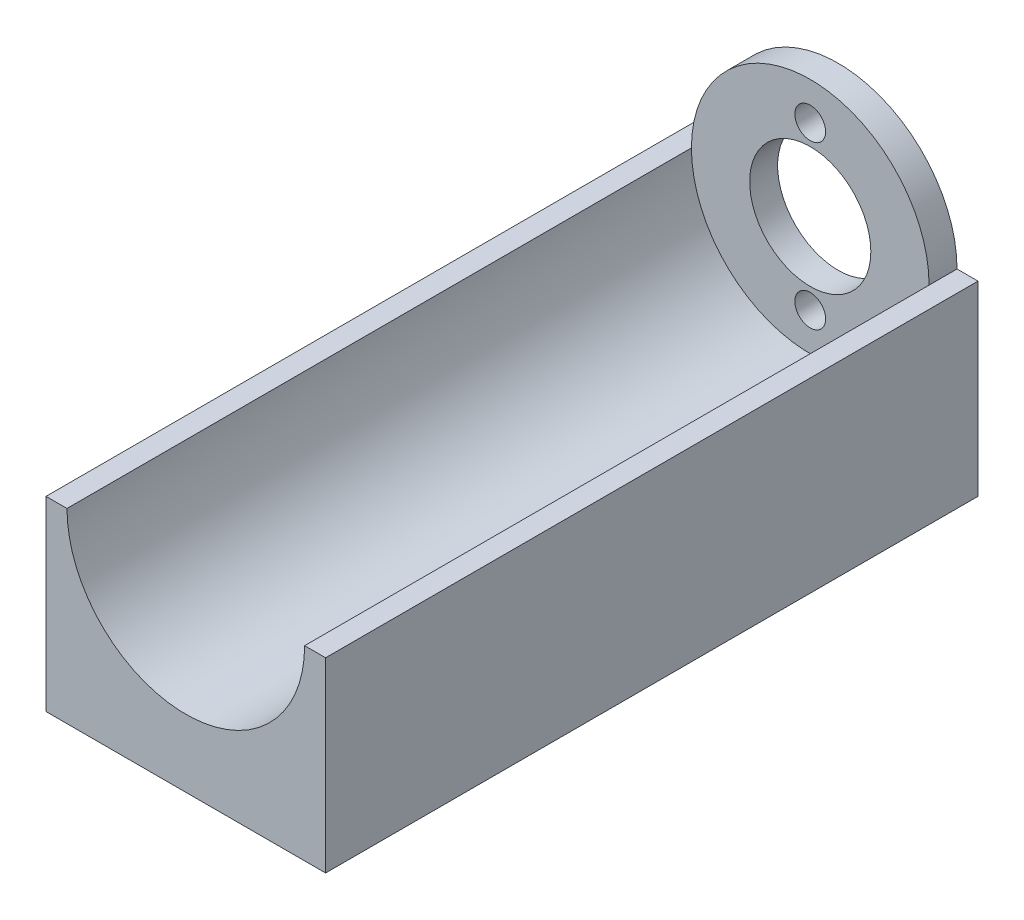
from build123d import *

# Parameters (mm, degrees)
SKETCH1_R                = 12.75
SKETCH1_R_2              = 6.5
BOSS_EXTRUDE1_DEPTH      = 3
BOSS_EXTRUDE2_DEPTH      = 67
BOSS_EXTRUDE2_DEPTH_BACK = 3
SKETCH4_R                = 2.515
CUT_EXTRUDE1_DEPTH       = 6
LPATTERN1_COUNT          = 2
LPATTERN1_PITCH          = 20
LPATTERN1_COUNT_DIR2     = 7
LPATTERN1_PITCH_DIR2     = 10
SKETCH5_R                = 1.65
CUT_EXTRUDE2_DEPTH       = 75


with BuildPart() as part:
    # Sketch1 → Boss-Extrude1 (new body)
    with BuildSketch(Plane.XY):
        Circle(SKETCH1_R)
        Circle(SKETCH1_R_2, mode=Mode.SUBTRACT)
    extrude(amount=BOSS_EXTRUDE1_DEPTH)

    # Sketch2 → Boss-Extrude2 (add, two sides)
    with BuildSketch(Plane.XY.offset(3)) as boss_extrude2_sk:
        with BuildLine():
            Line((15, -20), (15, 0))
            Line((15, 0), (12.75, 0))
            ThreePointArc((12.75, 0), (0, -12.75), (-12.75, 0))
            Line((-12.75, 0), (-15, 0))
            Line((-15, 0), (-15, -20))
            Line((-15, -20), (15, -20))
        make_face()
    extrude(amount=BOSS_EXTRUDE2_DEPTH)
    extrude(boss_extrude2_sk.sketch, amount=-BOSS_EXTRUDE2_DEPTH_BACK)

    # Sketch4 → Cut-Extrude1 (cut)
    with BuildSketch(Plane.XZ.offset(20)):
        with Locations((-10, 67)):
            Circle(SKETCH4_R)
    cut_extrude1 = extrude(amount=-CUT_EXTRUDE1_DEPTH, mode=Mode.SUBTRACT)

    # LPattern1: Cut-Extrude1 2 × 7
    with Locations(*[(i * LPATTERN1_PITCH, 0, -j * LPATTERN1_PITCH_DIR2) for i in range(LPATTERN1_COUNT) for j in range(LPATTERN1_COUNT_DIR2) if (i, j) != (0, 0)]):
        add(cut_extrude1, mode=Mode.SUBTRACT)

    # Sketch5 → Cut-Extrude2 (cut)
    with BuildSketch(Plane(origin=(0, 0, 0), x_dir=(-1, 0, 0), z_dir=(0, 0, -1))):
        with Locations((0, 8.7)):
            Circle(SKETCH5_R)
        with Locations((0, -8.7)):
            Circle(SKETCH5_R)
    extrude(amount=-CUT_EXTRUDE2_DEPTH, mode=Mode.SUBTRACT)


solid = part.part
